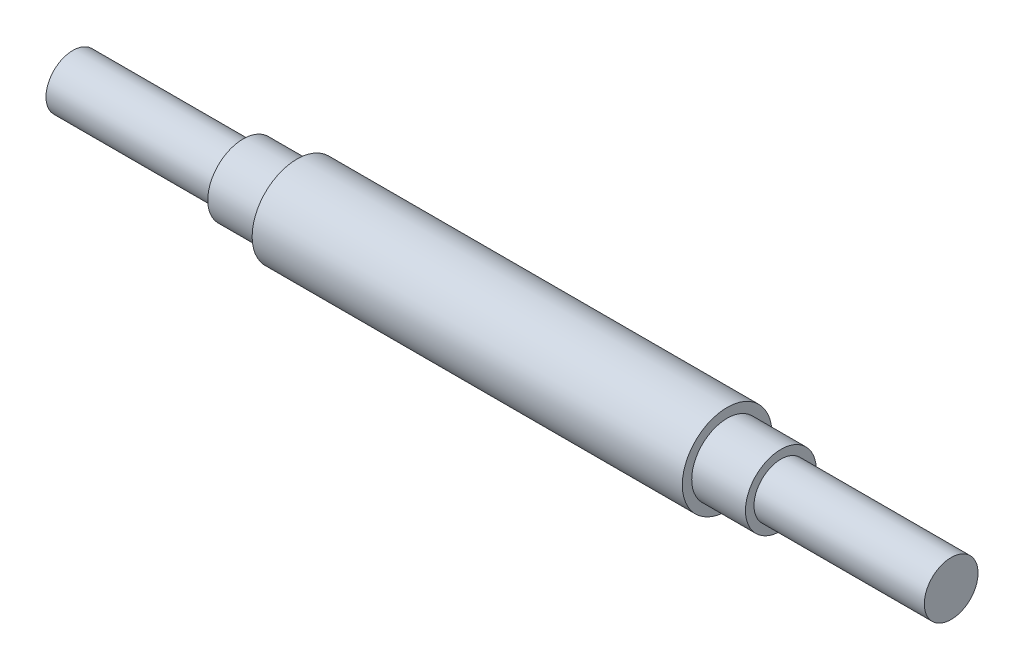
from build123d import *


with BuildPart() as part:
    # 草图1 → 旋转1 (revolve)
    with BuildSketch(Plane.XY):
        Polygon((-27.362637363, 0), (70.637362637, 0), (70.637362637, 3), (51.637362637, 3), (51.637362637, 3.95), (45.637362637, 3.95), (45.637362637, 5), (-2.362637363, 5), (-2.362637363, 3.95), (-8.362637363, 3.95), (-8.362637363, 3), (-27.362637363, 3), align=None)
    revolve(axis=Axis((-47.912087912, 0, 0), (1, 0, 0)))


solid = part.part
